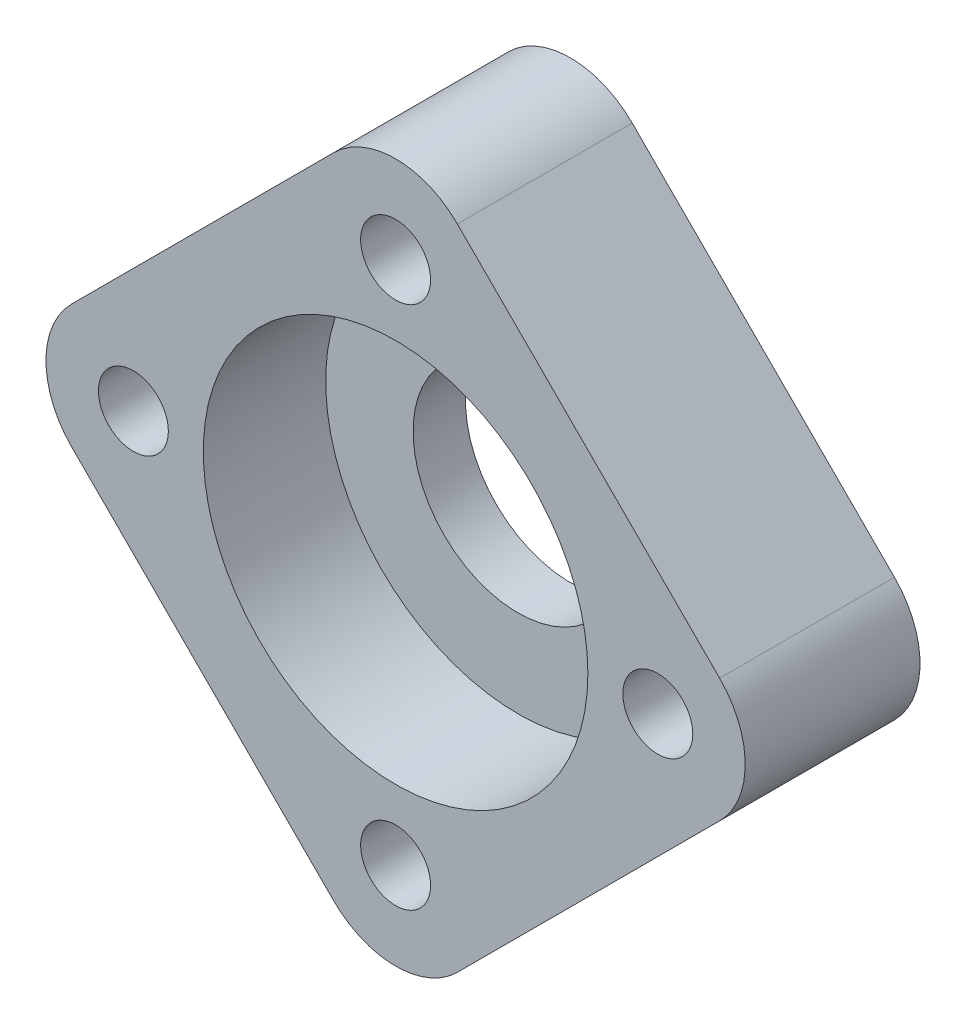
from build123d import *

# Parameters (mm, degrees)
SKETCH1_R           = 2
BOSS_EXTRUDE1_DEPTH = 10
SKETCH2_R           = 11
CUT_EXTRUDE1_DEPTH  = 7
SKETCH3_R           = 6
CUT_EXTRUDE2_DEPTH  = 7


with BuildPart() as part:
    # Sketch1 → Boss-Extrude1 (new body)
    with BuildSketch(Plane.XY):
        with BuildLine():
            Line((-18.535533906, 3.535533906), (-3.535533906, 18.535533906))
            ThreePointArc((-3.535533906, 18.535533906), (0, 20), (3.535533906, 18.535533906))
            Line((3.535533906, 18.535533906), (18.535533906, 3.535533906))
            ThreePointArc((18.535533906, 3.535533906), (20, 0), (18.535533906, -3.535533906))
            Line((18.535533906, -3.535533906), (3.535533906, -18.535533906))
            ThreePointArc((3.535533906, -18.535533906), (0, -20), (-3.535533906, -18.535533906))
            Line((-3.535533906, -18.535533906), (-18.535533906, -3.535533906))
            ThreePointArc((-18.535533906, -3.535533906), (-20, 0), (-18.535533906, 3.535533906))
        make_face()
        with Locations((0, 15)):
            Circle(SKETCH1_R, mode=Mode.SUBTRACT)
        with Locations((15, 0)):
            Circle(SKETCH1_R, mode=Mode.SUBTRACT)
        with Locations((0, -15)):
            Circle(SKETCH1_R, mode=Mode.SUBTRACT)
        with Locations((-15, 0)):
            Circle(SKETCH1_R, mode=Mode.SUBTRACT)
    extrude(amount=BOSS_EXTRUDE1_DEPTH)

    # Sketch2 → Cut-Extrude1 (cut)
    with BuildSketch(Plane.XY.offset(10)):
        Circle(SKETCH2_R)
    extrude(amount=-CUT_EXTRUDE1_DEPTH, mode=Mode.SUBTRACT)

    # Sketch3 → Cut-Extrude2 (cut)
    with BuildSketch(Plane.XY.offset(3)):
        Circle(SKETCH3_R)
    extrude(amount=-CUT_EXTRUDE2_DEPTH, mode=Mode.SUBTRACT)


solid = part.part
